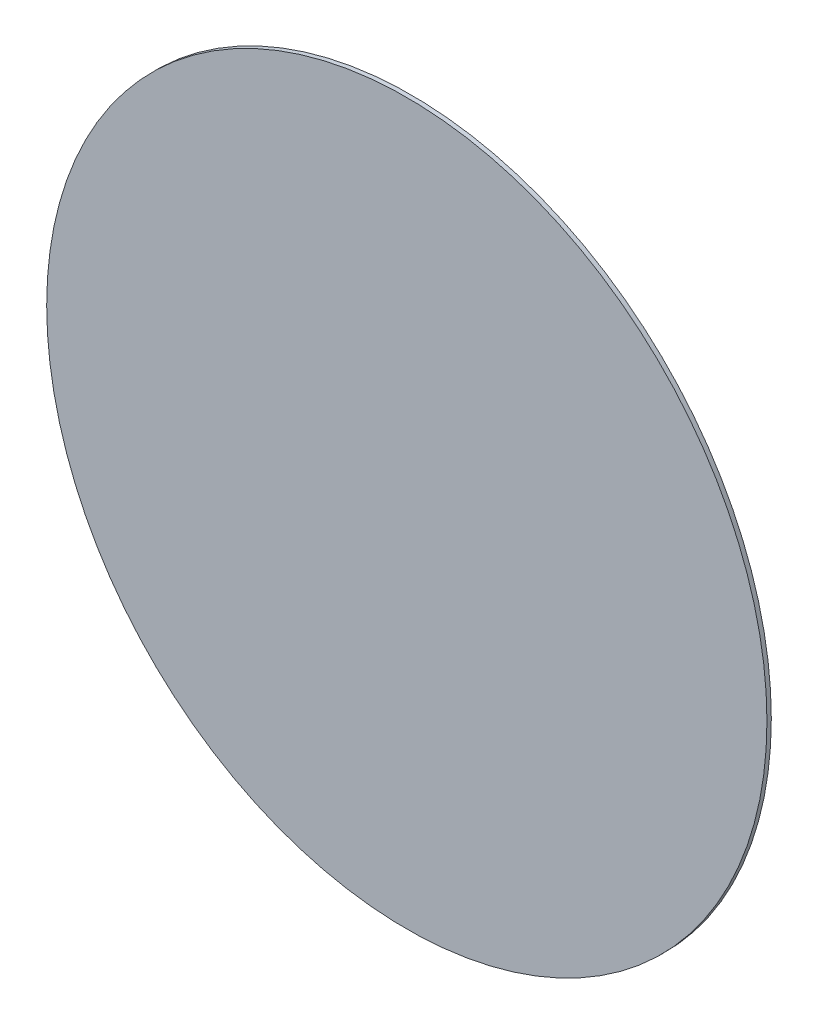
from build123d import *

# Parameters (mm, degrees)
SKETCH1_R           = 16.5
BOSS_EXTRUDE1_DEPTH = 0.2


with BuildPart() as part:
    # Sketch1 → Boss-Extrude1 (new body)
    with BuildSketch(Plane.XY):
        Circle(SKETCH1_R)
    extrude(amount=BOSS_EXTRUDE1_DEPTH)


solid = part.part
